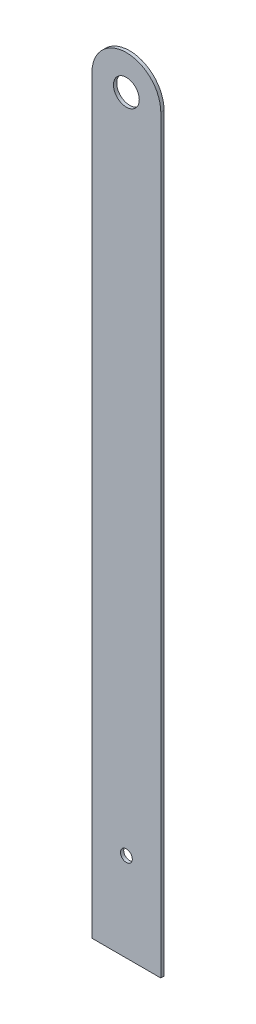
from build123d import *

# Parameters (mm, degrees)
SKETCH1_W           = 25.4
SKETCH1_H           = 276.86
BOSS_EXTRUDE1_DEPTH = 1.2
SKETCH2_R           = 4.7625
CUT_EXTRUDE1_DEPTH  = 2.2
SKETCH3_R           = 2.1827998
CUT_EXTRUDE2_DEPTH  = 2.2


with BuildPart() as part:
    # Sketch1 → Boss-Extrude1 (new body)
    with BuildSketch(Plane.XY):
        Rectangle(SKETCH1_W, SKETCH1_H)
        with BuildLine():
            ThreePointArc((-12.7, 138.43), (0, 151.13), (12.7, 138.43))
            Line((12.7, 138.43), (-12.7, 138.43))
        make_face()
    extrude(amount=BOSS_EXTRUDE1_DEPTH)

    # Sketch2 → Cut-Extrude1 (cut, through all)
    with BuildSketch(Plane.XY.offset(1.2)):
        with Locations((0, 138.43)):
            Circle(SKETCH2_R)
    extrude(amount=-CUT_EXTRUDE1_DEPTH, mode=Mode.SUBTRACT)

    # Sketch3 → Cut-Extrude2 (cut, through all)
    with BuildSketch(Plane.XY.offset(1.2)):
        with Locations((0, -105.668572)):
            Circle(SKETCH3_R)
    extrude(amount=-CUT_EXTRUDE2_DEPTH, mode=Mode.SUBTRACT)


solid = part.part
